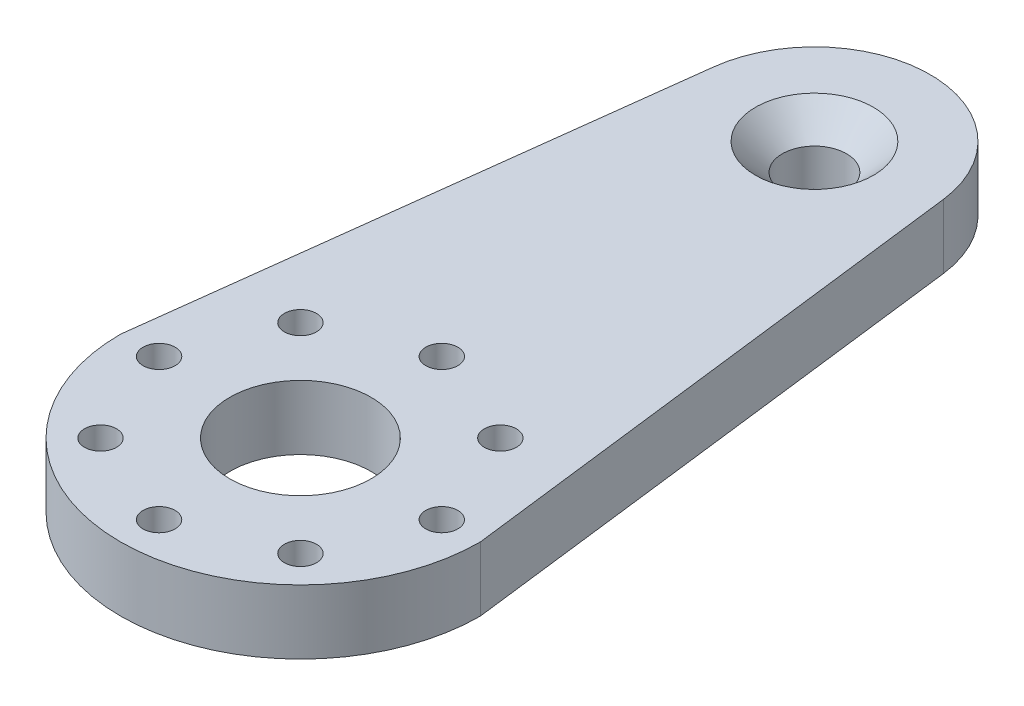
from build123d import *

# Parameters (mm, degrees)
SKETCH1_R                                            = 2.5
SKETCH1_R_2                                          = 5.5
BOSS_EXTRUDE1_DEPTH                                  = 5
SKETCH2_R                                            = 1.25
CUT_EXTRUDE1_DEPTH                                   = 6
CUT_EXTRUDE2_DEPTH                                   = 6
CSK_FOR_M4_HEX_SOCKET_COUNTERSUNK_HEAD_S_D           = 4.5
CSK_FOR_M4_HEX_SOCKET_COUNTERSUNK_HEAD_S_CSINK_D     = 9.18
CSK_FOR_M4_HEX_SOCKET_COUNTERSUNK_HEAD_S_CSINK_ANGLE = 90


with BuildPart() as part:
    # Sketch1 → Boss-Extrude1 (new body)
    with BuildSketch(Plane(origin=(0, 0, 0), x_dir=(1, 0, 0), z_dir=(0, 1, 0))):
        with BuildLine():
            Line((-14, 0), (-14, 40))
            ThreePointArc((-14, 40), (0, 54), (14, 40))
            Line((14, 40), (14, 0))
            ThreePointArc((14, 0), (0, -14), (-14, 0))
        make_face()
        with Locations((0, 40)):
            Circle(SKETCH1_R, mode=Mode.SUBTRACT)
        Circle(SKETCH1_R_2, mode=Mode.SUBTRACT)
    extrude(amount=BOSS_EXTRUDE1_DEPTH)

    # Sketch2 → Cut-Extrude1 (cut, through all)
    with BuildSketch(Plane(origin=(0, 5, 0), x_dir=(1, 0, 0), z_dir=(0, 1, 0))):
        with Locations((0, 11)):
            Circle(SKETCH2_R)
        with Locations((7.778174593, 7.778174593)):
            Circle(SKETCH2_R)
        with Locations((11, 0)):
            Circle(SKETCH2_R)
        with Locations((7.778174593, -7.778174593)):
            Circle(SKETCH2_R)
        with Locations((0, -11)):
            Circle(SKETCH2_R)
        with Locations((-7.778174593, -7.778174593)):
            Circle(SKETCH2_R)
        with Locations((-11, 0)):
            Circle(SKETCH2_R)
        with Locations((-7.778174593, 7.778174593)):
            Circle(SKETCH2_R)
    extrude(amount=-CUT_EXTRUDE1_DEPTH, mode=Mode.SUBTRACT)

    # Sketch3 → Cut-Extrude2 (cut, through all)
    with BuildSketch(Plane(origin=(0, 5, 0), x_dir=(1, 0, 0), z_dir=(0, 1, 0))):
        with BuildLine():
            Line((-14, 40), (-14, 0))
            Line((-14, 0), (-8.932361388, 41.101326486))
            ThreePointArc((-8.932361388, 41.101326486), (0, 49), (8.932361388, 41.101326486))
            Line((8.932361388, 41.101326486), (14, 0))
            Line((14, 0), (14, 40))
            ThreePointArc((14, 40), (0, 54), (-14, 40))
        make_face()
    extrude(amount=-CUT_EXTRUDE2_DEPTH, mode=Mode.SUBTRACT)

    # CSK for M4 Hex Socket Countersunk Head Screw2 (through all)
    with Locations(Plane(origin=(0, 5, 0), x_dir=(1, 0, 0), z_dir=(0, 1, 0))):
        with Locations((0, 40)):
            CounterSinkHole(CSK_FOR_M4_HEX_SOCKET_COUNTERSUNK_HEAD_S_D / 2, CSK_FOR_M4_HEX_SOCKET_COUNTERSUNK_HEAD_S_CSINK_D / 2, counter_sink_angle=CSK_FOR_M4_HEX_SOCKET_COUNTERSUNK_HEAD_S_CSINK_ANGLE)


solid = part.part
